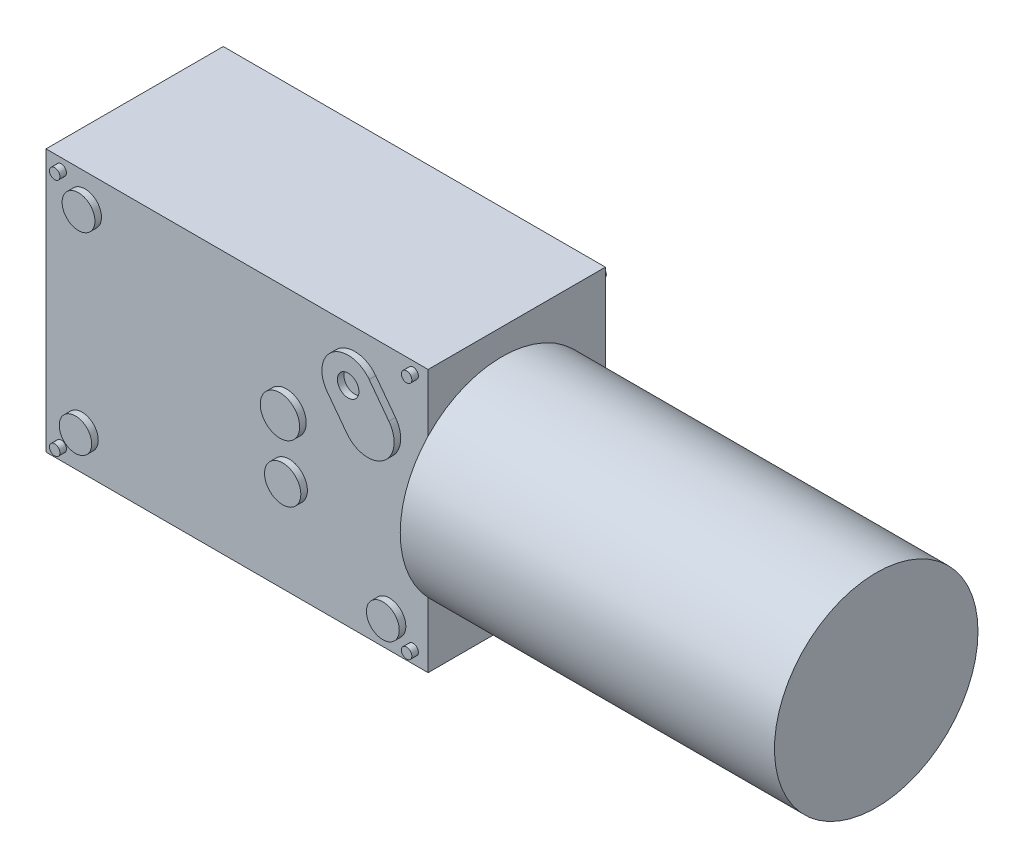
from build123d import *

# Parameters (mm, degrees)
ESQUISSE1_W        = 58.2
ESQUISSE1_H        = 40
BOSS_EXTRU_1_DEPTH = 27
ESQUISSE2_R        = 15.5
BOSS_EXTRU_2_DEPTH = 57
ESQUISSE3_R        = 0.796993634
ESQUISSE3_R_2      = 3
ESQUISSE3_R_3      = 2.5
ESQUISSE3_R_4      = 1.643785586
BOSS_EXTRU_3_DEPTH = 1
ESQUISSE4_R        = 0.796993634
ESQUISSE4_R_2      = 3
ESQUISSE4_R_3      = 2.765269511
ESQUISSE4_R_4      = 2.5
ESQUISSE4_R_5      = 2.472480212
ESQUISSE4_R_6      = 1.643785586
BOSS_EXTRU_4_DEPTH = 1
ESQUISSE5_R        = 8.5
BOSS_EXTRU_5_DEPTH = 2
ESQUISSE6_R        = 3.91408695
BOSS_EXTRU_6_DEPTH = 13


with BuildPart() as part:
    # Esquisse1 → Boss.-Extru.1 (new body)
    with BuildSketch(Plane.XY):
        with Locations((-1.276315789, -5.258552632)):
            Rectangle(ESQUISSE1_W, ESQUISSE1_H)
    extrude(amount=BOSS_EXTRU_1_DEPTH)

    # Esquisse2 → Boss.-Extru.2 (add)
    with BuildSketch(Plane(origin=(27.823684211, 0, 0), x_dir=(0, 0, -1), z_dir=(1, 0, 0))):
        with Locations((-15.74475958, -4.690804329)):
            Circle(ESQUISSE2_R)
    extrude(amount=BOSS_EXTRU_2_DEPTH)

    # Esquisse3 → Boss.-Extru.3 (add)
    with BuildSketch(Plane(origin=(0, 0, 0), x_dir=(-1, 0, 0), z_dir=(0, 0, -1))):
        with Locations((28.393888361, 12.845029268)):
            Circle(ESQUISSE3_R)
        with Locations((28.393888361, -23.584885169)):
            Circle(ESQUISSE3_R)
        with Locations((-26.168877972, 12.845029268)):
            Circle(ESQUISSE3_R)
        with Locations((-26.168877972, -23.584885169)):
            Circle(ESQUISSE3_R)
        with Locations((23.719200753, 10.39595939)):
            Circle(ESQUISSE3_R_2)
        with Locations((23.719200753, -20.319458665)):
            Circle(ESQUISSE3_R_2)
        with Locations((-21.69063657, -20.319458665)):
            Circle(ESQUISSE3_R_3)
        with Locations((-5.740000065, -0.085037149)):
            Circle(ESQUISSE3_R_3)
        with Locations((-5.569925768, -9.387416532)):
            Circle(ESQUISSE3_R_3)
        with BuildLine():
            Line((-16.903552301, 11.389352188), (-13.903552301, 7.389352188))
            ThreePointArc((-13.903552301, 7.389352188), (-14.703552301, 1.789352188), (-20.303552301, 2.589352188))
            Line((-20.303552301, 2.589352188), (-23.303552301, 6.589352188))
            ThreePointArc((-23.303552301, 6.589352188), (-22.503552301, 12.189352188), (-16.903552301, 11.389352188))
        make_face()
        with Locations((-20.103552301, 8.989352188)):
            Circle(ESQUISSE3_R_4, mode=Mode.SUBTRACT)
    extrude(amount=BOSS_EXTRU_3_DEPTH)

    # Esquisse4 → Boss.-Extru.4 (add)
    with BuildSketch(Plane.XY.offset(27)):
        with Locations((25.547055264, 13.126910984)):
            Circle(ESQUISSE4_R)
        with Locations((25.547055264, -23.303003453)):
            Circle(ESQUISSE4_R)
        with Locations((-28.053751612, 13.126910984)):
            Circle(ESQUISSE4_R)
        with Locations((-28.053751612, -23.303003453)):
            Circle(ESQUISSE4_R)
        with Locations((6.254872146, -1.609813965)):
            Circle(ESQUISSE4_R_2)
        with Locations((6.671158294, -10.421952213)):
            Circle(ESQUISSE4_R_3)
        with Locations((-24.425601337, 9.932760917)):
            Circle(ESQUISSE4_R_4)
        with Locations((21.931193301, -20.852114314)):
            Circle(ESQUISSE4_R_4)
        with Locations((-24.889302534, -19.715256897)):
            Circle(ESQUISSE4_R_5)
        with BuildLine():
            Line((19.844554955, 9.933092183), (22.844554955, 5.933092183))
            ThreePointArc((22.844554955, 5.933092183), (22.044554955, 0.333092183), (16.444554955, 1.133092183))
            Line((16.444554955, 1.133092183), (13.444554955, 5.133092183))
            ThreePointArc((13.444554955, 5.133092183), (14.244554955, 10.733092183), (19.844554955, 9.933092183))
        make_face()
        with Locations((16.644554955, 7.533092183)):
            Circle(ESQUISSE4_R_6, mode=Mode.SUBTRACT)
    extrude(amount=BOSS_EXTRU_4_DEPTH)

    # Esquisse5 → Boss.-Extru.5 (add)
    with BuildSketch(Plane(origin=(0, 0, 0), x_dir=(-1, 0, 0), z_dir=(0, 0, -1))):
        with Locations((10.376315789, -4.734018324)):
            Circle(ESQUISSE5_R)
    extrude(amount=BOSS_EXTRU_5_DEPTH)

    # Esquisse6 → Boss.-Extru.6 (add)
    with BuildSketch(Plane(origin=(0, 0, 0), x_dir=(-1, 0, 0), z_dir=(0, 0, -1))):
        with Locations((10.361829536, -4.723039304)):
            Circle(ESQUISSE6_R)
    extrude(amount=BOSS_EXTRU_6_DEPTH)


solid = part.part
